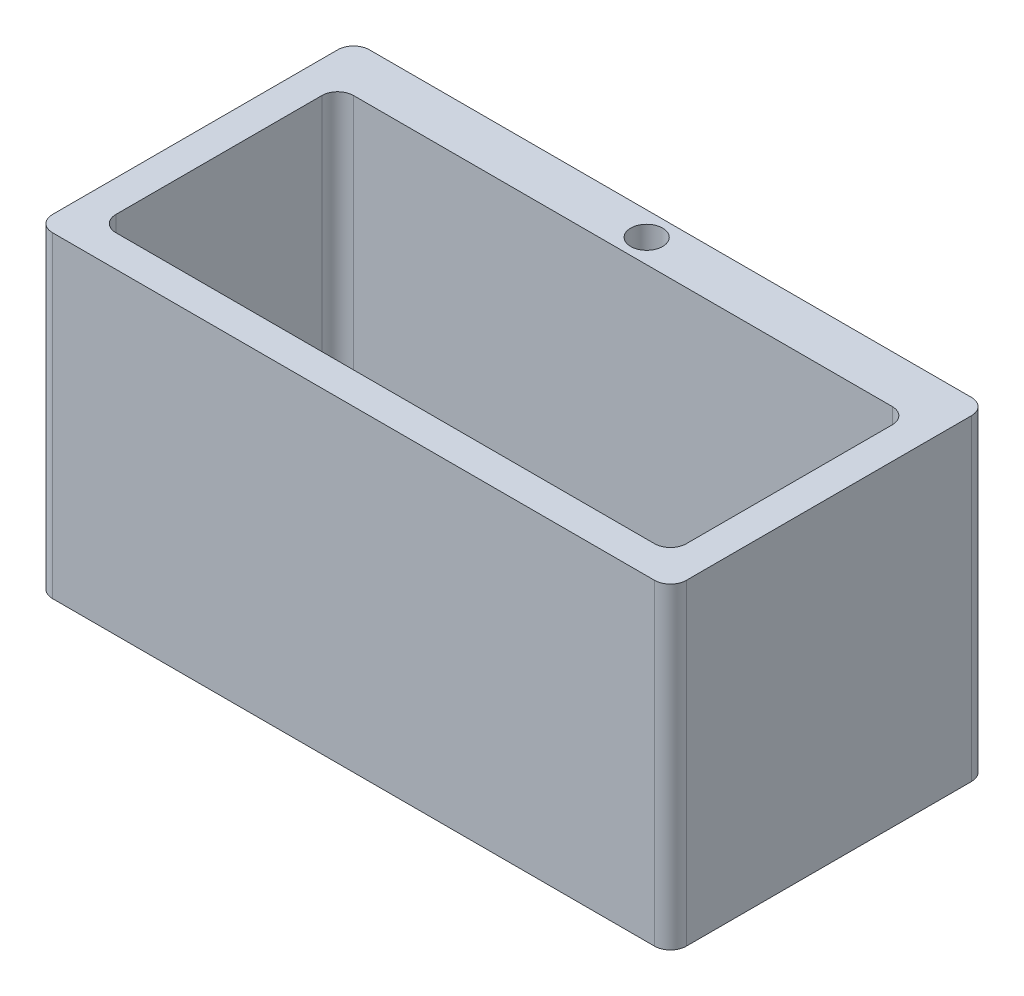
from build123d import *

# Parameters (mm, degrees)
SKETCH1_R           = 12.811295034
SKETCH1_R_2         = 19.687662737
BOSS_EXTRUDE1_DEPTH = 254
CUT_EXTRUDE1_DEPTH  = 241.3


with BuildPart() as part:
    # Sketch1 → Boss-Extrude1 (new body)
    with BuildSketch(Plane(origin=(0, 0, 0), x_dir=(1, 0, 0), z_dir=(0, 1, 0))):
        with BuildLine():
            Line((-133.764264849, 68.038364167), (348.835735151, 68.038364167))
            ThreePointArc((348.835735151, 68.038364167), (357.815991272, 64.318620289), (361.535735151, 55.338364167))
            Line((361.535735151, 55.338364167), (361.535735151, -173.261635833))
            ThreePointArc((361.535735151, -173.261635833), (357.815991272, -182.241891954), (348.835735151, -185.961635833))
            Line((348.835735151, -185.961635833), (-133.764264849, -185.961635833))
            ThreePointArc((-133.764264849, -185.961635833), (-142.74452097, -182.241891954), (-146.464264849, -173.261635833))
            Line((-146.464264849, -173.261635833), (-146.464264849, 55.338364167))
            ThreePointArc((-146.464264849, 55.338364167), (-142.74452097, 64.318620289), (-133.764264849, 68.038364167))
        make_face()
        with Locations((107.535735151, 48.988364167)):
            Circle(SKETCH1_R, mode=Mode.SUBTRACT)
        with Locations((107.535735151, -69.423369036)):
            Circle(SKETCH1_R_2, mode=Mode.SUBTRACT)
    extrude(amount=-BOSS_EXTRUDE1_DEPTH)

    # Sketch2 → Cut-Extrude1 (cut)
    with BuildSketch(Plane(origin=(0, 0, 0), x_dir=(1, 0, 0), z_dir=(0, 1, 0))):
        with BuildLine():
            Line((-108.364264849, 29.938364167), (323.435735151, 29.938364167))
            ThreePointArc((323.435735151, 29.938364167), (332.415991272, 26.218620289), (336.135735151, 17.238364167))
            Line((336.135735151, 17.238364167), (336.135735151, -147.861635833))
            ThreePointArc((336.135735151, -147.861635833), (332.415991272, -156.841891954), (323.435735151, -160.561635833))
            Line((323.435735151, -160.561635833), (-108.364264849, -160.561635833))
            ThreePointArc((-108.364264849, -160.561635833), (-117.34452097, -156.841891954), (-121.064264849, -147.861635833))
            Line((-121.064264849, -147.861635833), (-121.064264849, 17.238364167))
            ThreePointArc((-121.064264849, 17.238364167), (-117.34452097, 26.218620289), (-108.364264849, 29.938364167))
        make_face()
    extrude(amount=-CUT_EXTRUDE1_DEPTH, mode=Mode.SUBTRACT)


solid = part.part
